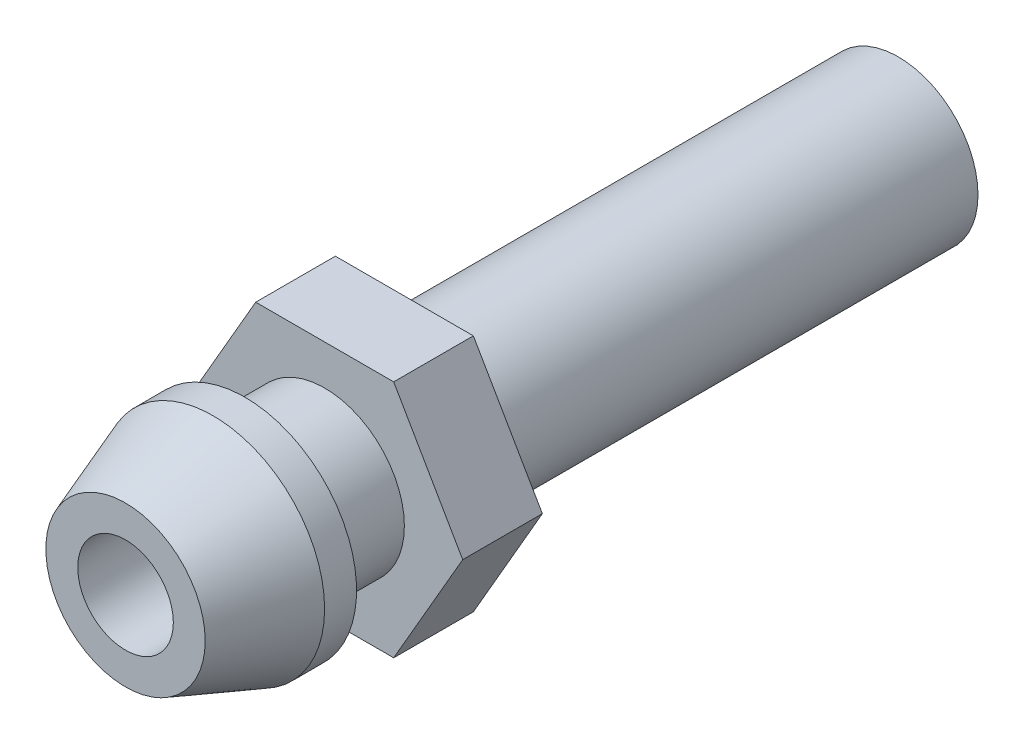
from build123d import *

# Parameters (mm, degrees)
SKETCH1_R           = 1.27
BOSS_EXTRUDE1_DEPTH = 6.35
SKETCH2_R           = 1.27
BOSS_EXTRUDE2_DEPTH = 0.254
SKETCH3_R           = 1.27
BOSS_EXTRUDE3_DEPTH = 1.27
BOSS_EXTRUDE4_DEPTH = 1.27
SKETCH5_R           = 1.27
BOSS_EXTRUDE5_DEPTH = 1.27
SKETCH6_R           = 1.27
BOSS_EXTRUDE6_DEPTH = 1.905
DRAFT3_ANGLE        = 20
SKETCH7_R           = 0.762
CUT_EXTRUDE1_DEPTH  = 13.319
SKETCH8_R           = 1.963363296
SKETCH8_R_2         = 1.778
CUT_EXTRUDE2_DEPTH  = 2.54


with BuildPart() as part:
    # Sketch1 → Boss-Extrude1 (new body)
    with BuildSketch(Plane.XY):
        Circle(SKETCH1_R)
    extrude(amount=BOSS_EXTRUDE1_DEPTH)

    # Sketch2 → Boss-Extrude2 (add)
    with BuildSketch(Plane.XY.offset(6.35)):
        Circle(SKETCH2_R)
    extrude(amount=BOSS_EXTRUDE2_DEPTH)

    # Sketch3 → Boss-Extrude3 (add)
    with BuildSketch(Plane.XY.offset(6.604)):
        Circle(SKETCH3_R)
    extrude(amount=BOSS_EXTRUDE3_DEPTH)

    # Sketch4 → Boss-Extrude4 (add)
    with BuildSketch(Plane.XY.offset(7.874)):
        Polygon((2.199704526, 0), (1.099852263, 1.905), (-1.099852263, 1.905), (-2.199704526, 0), (-1.099852263, -1.905), (1.099852263, -1.905), align=None)
    extrude(amount=BOSS_EXTRUDE4_DEPTH)

    # Sketch5 → Boss-Extrude5 (add)
    with BuildSketch(Plane.XY.offset(9.144)):
        Circle(SKETCH5_R)
    extrude(amount=BOSS_EXTRUDE5_DEPTH)


with BuildPart() as body_2:
    # Sketch6 → Boss-Extrude6 (new body)
    with BuildSketch(Plane.XY.offset(10.414)):
        Circle(SKETCH6_R)
    extrude(amount=BOSS_EXTRUDE6_DEPTH)

    # Draft3
    draft3_faces = [body_2.faces().sort_by_distance(p)[0] for p in [
        (-1.27, 0, 11.3665),
    ]]
    draft(draft3_faces, Plane.XY.offset(12.319), DRAFT3_ANGLE)


with BuildPart() as cut_extrude1_tool:
    # Sketch7 → Cut-Extrude1 (new body, through all)
    with BuildSketch(Plane.XY.offset(12.319)):
        Circle(SKETCH7_R)
    extrude(amount=-CUT_EXTRUDE1_DEPTH)


with BuildPart() as part_1:
    add(part.part)

    # Cut-Extrude1: cut by cut_extrude1_tool
    add(cut_extrude1_tool.part, mode=Mode.SUBTRACT)


with BuildPart() as body_2_1:
    add(body_2.part)

    # Cut-Extrude1: cut by cut_extrude1_tool
    add(cut_extrude1_tool.part, mode=Mode.SUBTRACT)

    # Sketch8 → Cut-Extrude2 (cut)
    with BuildSketch(Plane(origin=(0, 0, 10.414), x_dir=(-1, 0, 0), z_dir=(0, 0, -1))):
        Circle(SKETCH8_R)
        Circle(SKETCH8_R_2, mode=Mode.SUBTRACT)
    extrude(amount=-CUT_EXTRUDE2_DEPTH, mode=Mode.SUBTRACT)


solid = Compound([part_1.part, body_2_1.part])
